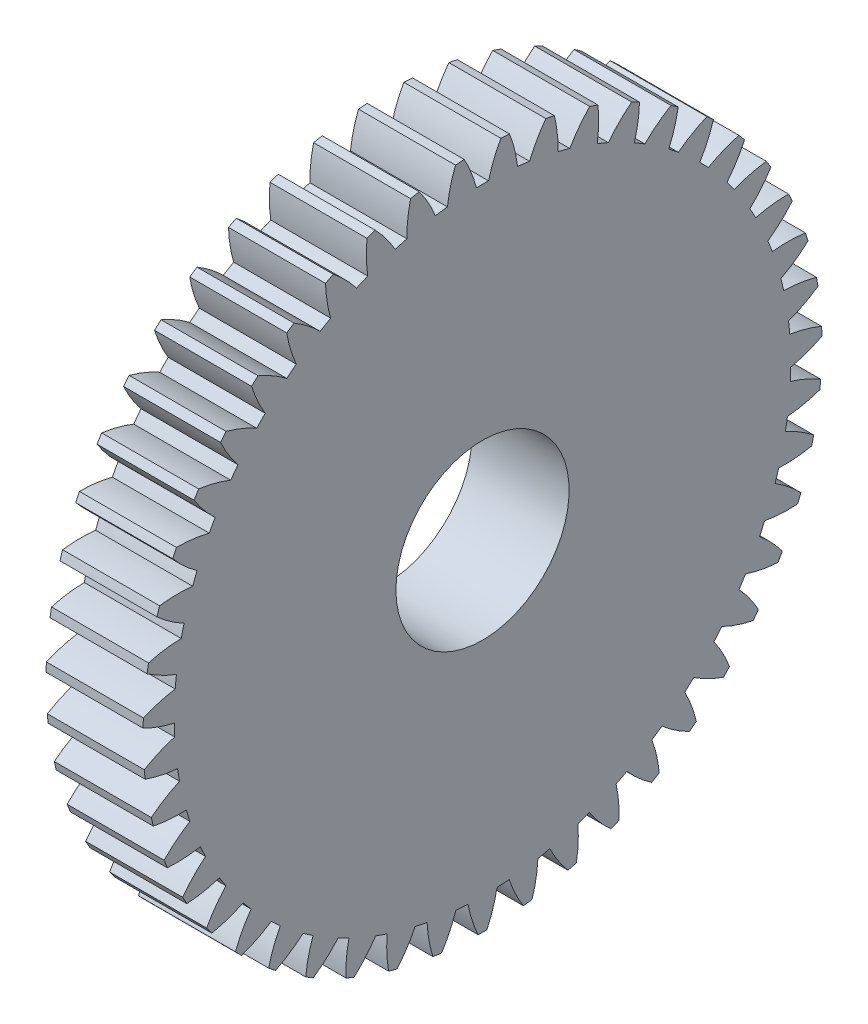
from build123d import *

# Parameters (mm, degrees)
BASPROSKE_W     = 2.8
BASPROSKE_H     = 9.8
TOOTHCUT_DEPTH  = 15.139306914
TEETHCUTS_COUNT = 47
TEETHCUTS_ANGLE = 352.340425532
BORSKE_R        = 2.5
BORE_DEPTH      = 50.0000508


with BuildPart() as part:
    # BasProSke → Base-Revolve (revolve)
    with BuildSketch(Plane(origin=(0, 0, 0), x_dir=(1, 0, 0), z_dir=(0, 1, 0)), mode=Mode.PRIVATE) as base_revolve_sk:
        with Locations((1.4, 4.9)):
            Rectangle(BASPROSKE_W, BASPROSKE_H)
    revolve(base_revolve_sk.sketch.rotate(Axis((-10, 0, 0), (1, 0, 0)), 180), axis=Axis((-10, 0, 0), (1, 0, 0)))

    # TooCutSke → ToothCut (cut, through all)
    with BuildSketch(Plane(origin=(0, 0, 0), x_dir=(0, 0, -1), z_dir=(1, 0, 0))):
        with BuildLine():
            ThreePointArc((0.175716906, 8.897265005), (0, 8.899), (-0.175716906, 8.897265005))
            ThreePointArc((-0.175716906, 8.897265005), (-0.328998501, 9.365887362), (-0.542281085, 9.810423864))
            ThreePointArc((-0.542281085, 9.810423864), (0, 9.8254), (0.542281085, 9.810423864))
            ThreePointArc((0.542281085, 9.810423864), (0.328998501, 9.365887362), (0.175716906, 8.897265005))
        make_face()
    toothcut = extrude(amount=TOOTHCUT_DEPTH, mode=Mode.SUBTRACT)

    # TeethCuts: ToothCut ×47 about axis
    teethcuts_axis = Axis((-10, 0, 0), (1, 0, 0))
    for i in range(1, TEETHCUTS_COUNT):
        add(toothcut.rotate(teethcuts_axis, i * TEETHCUTS_ANGLE / (TEETHCUTS_COUNT - 1)), mode=Mode.SUBTRACT)

    # BorSke → Bore (cut, symmetric)
    with BuildSketch(Plane(origin=(0, 0, 0), x_dir=(0, 0, -1), z_dir=(1, 0, 0))):
        with Locations(Location((0, 0, 0), (0, 0, 180))):
            Circle(BORSKE_R)
    extrude(amount=BORE_DEPTH, both=True, mode=Mode.SUBTRACT)


solid = part.part
